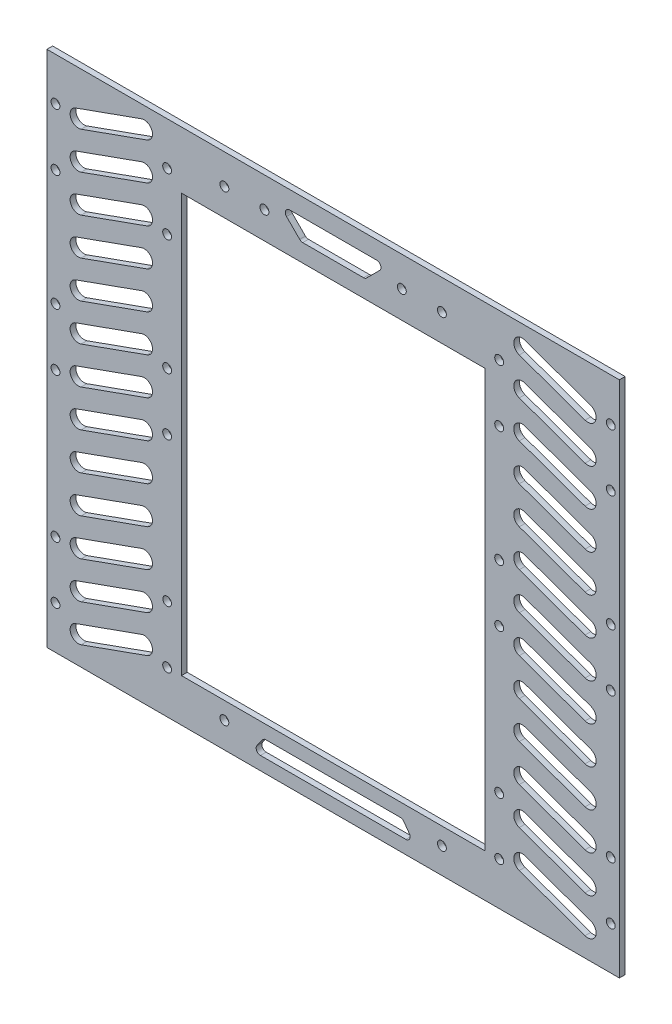
from build123d import *

# Parameters (mm, degrees)
SKETCH_1_R      = 1.55
SKETCH_1_R_2    = 1.51
SKETCH_1_W      = 106
SKETCH_1_H      = 146
EXTRUDE_1_DEPTH = 2


with BuildPart() as part:
    # 草图1 → 凸台-拉伸1 (new body)
    with BuildSketch(Plane.XY):
        Polygon((-100, 62.5), (-100, -62.5), (-100, -90.5), (100, -90.5), (100, -62.5), (100, 62.5), (100, 90.5), (-100, 90.5), align=None)
        with Locations((-97, -75.5)):
            Circle(SKETCH_1_R, mode=Mode.SUBTRACT)
        with Locations((-97, -55.5)):
            Circle(SKETCH_1_R, mode=Mode.SUBTRACT)
        with Locations((-97, 75.5)):
            Circle(SKETCH_1_R, mode=Mode.SUBTRACT)
        with Locations((-97, 55.5)):
            Circle(SKETCH_1_R, mode=Mode.SUBTRACT)
        with Locations((-97, -5)):
            Circle(SKETCH_1_R, mode=Mode.SUBTRACT)
        with Locations((-97, 15)):
            Circle(SKETCH_1_R, mode=Mode.SUBTRACT)
        with Locations((97, 75.5)):
            Circle(SKETCH_1_R, mode=Mode.SUBTRACT)
        with Locations((97, 55.5)):
            Circle(SKETCH_1_R, mode=Mode.SUBTRACT)
        with Locations((97, -55.5)):
            Circle(SKETCH_1_R, mode=Mode.SUBTRACT)
        with Locations((97, -75.5)):
            Circle(SKETCH_1_R, mode=Mode.SUBTRACT)
        with Locations((-58, 75.5)):
            Circle(SKETCH_1_R, mode=Mode.SUBTRACT)
        with Locations((-58, 55.5)):
            Circle(SKETCH_1_R, mode=Mode.SUBTRACT)
        with Locations((-58, -55.5)):
            Circle(SKETCH_1_R_2, mode=Mode.SUBTRACT)
        with Locations((-58, -75.5)):
            Circle(SKETCH_1_R, mode=Mode.SUBTRACT)
        with Locations((58, 75.5)):
            Circle(SKETCH_1_R, mode=Mode.SUBTRACT)
        with Locations((58, 55.5)):
            Circle(SKETCH_1_R, mode=Mode.SUBTRACT)
        with Locations((58, -75.5)):
            Circle(SKETCH_1_R, mode=Mode.SUBTRACT)
        with Locations((58, -55.5)):
            Circle(SKETCH_1_R, mode=Mode.SUBTRACT)
        with Locations((-58, -5)):
            Circle(SKETCH_1_R, mode=Mode.SUBTRACT)
        with Locations((-58, 15)):
            Circle(SKETCH_1_R, mode=Mode.SUBTRACT)
        with Locations((97, 15)):
            Circle(SKETCH_1_R, mode=Mode.SUBTRACT)
        with Locations((97, -5)):
            Circle(SKETCH_1_R, mode=Mode.SUBTRACT)
        with Locations((58, 15)):
            Circle(SKETCH_1_R, mode=Mode.SUBTRACT)
        with Locations((58, -5)):
            Circle(SKETCH_1_R, mode=Mode.SUBTRACT)
        with Locations((-38, 80)):
            Circle(SKETCH_1_R, mode=Mode.SUBTRACT)
        with Locations((-24, 80)):
            Circle(SKETCH_1_R, mode=Mode.SUBTRACT)
        with Locations((24, 80)):
            Circle(SKETCH_1_R, mode=Mode.SUBTRACT)
        with Locations((38, 80)):
            Circle(SKETCH_1_R, mode=Mode.SUBTRACT)
        with Locations((-38, -81.5)):
            Circle(SKETCH_1_R, mode=Mode.SUBTRACT)
        with Locations((38, -81.5)):
            Circle(SKETCH_1_R, mode=Mode.SUBTRACT)
        with Locations((0, -2.5)):
            Rectangle(SKETCH_1_W, SKETCH_1_H, mode=Mode.SUBTRACT)
        with BuildLine():
            Line((-65.024906734, 80.53970658), (-88.024906734, 72.307350493))
            ThreePointArc((-88.024906734, 72.307350493), (-91.724268106, 74.056525332), (-89.975093266, 77.755886704))
            Line((-89.975093266, 77.755886704), (-66.975093266, 85.988242791))
            ThreePointArc((-66.975093266, 85.988242791), (-63.275731894, 84.239067952), (-65.024906734, 80.53970658))
        make_face(mode=Mode.SUBTRACT)
        with BuildLine():
            Line((-65.024906734, 67.53970658), (-88.024906734, 59.307350493))
            ThreePointArc((-88.024906734, 59.307350493), (-91.724268106, 61.056525332), (-89.975093266, 64.755886704))
            Line((-89.975093266, 64.755886704), (-66.975093266, 72.988242791))
            ThreePointArc((-66.975093266, 72.988242791), (-63.275731894, 71.239067952), (-65.024906734, 67.53970658))
        make_face(mode=Mode.SUBTRACT)
        with BuildLine():
            Line((-65.024906734, 54.53970658), (-88.024906734, 46.307350493))
            ThreePointArc((-88.024906734, 46.307350493), (-91.724268106, 48.056525332), (-89.975093266, 51.755886704))
            Line((-89.975093266, 51.755886704), (-66.975093266, 59.988242791))
            ThreePointArc((-66.975093266, 59.988242791), (-63.275731894, 58.239067952), (-65.024906734, 54.53970658))
        make_face(mode=Mode.SUBTRACT)
        with BuildLine():
            Line((-65.024906734, 41.53970658), (-88.024906734, 33.307350493))
            ThreePointArc((-88.024906734, 33.307350493), (-91.724268106, 35.056525332), (-89.975093266, 38.755886704))
            Line((-89.975093266, 38.755886704), (-66.975093266, 46.988242791))
            ThreePointArc((-66.975093266, 46.988242791), (-63.275731894, 45.239067952), (-65.024906734, 41.53970658))
        make_face(mode=Mode.SUBTRACT)
        with BuildLine():
            Line((-65.024906734, 28.53970658), (-88.024906734, 20.307350493))
            ThreePointArc((-88.024906734, 20.307350493), (-91.724268106, 22.056525332), (-89.975093266, 25.755886704))
            Line((-89.975093266, 25.755886704), (-66.975093266, 33.988242791))
            ThreePointArc((-66.975093266, 33.988242791), (-63.275731894, 32.239067952), (-65.024906734, 28.53970658))
        make_face(mode=Mode.SUBTRACT)
        with BuildLine():
            Line((-65.024906734, 15.53970658), (-88.024906734, 7.307350493))
            ThreePointArc((-88.024906734, 7.307350493), (-91.724268106, 9.056525332), (-89.975093266, 12.755886704))
            Line((-89.975093266, 12.755886704), (-66.975093266, 20.988242791))
            ThreePointArc((-66.975093266, 20.988242791), (-63.275731894, 19.239067952), (-65.024906734, 15.53970658))
        make_face(mode=Mode.SUBTRACT)
        with BuildLine():
            Line((-65.024906734, 2.53970658), (-88.024906734, -5.692649507))
            ThreePointArc((-88.024906734, -5.692649507), (-91.724268106, -3.943474668), (-89.975093266, -0.244113296))
            Line((-89.975093266, -0.244113296), (-66.975093266, 7.988242791))
            ThreePointArc((-66.975093266, 7.988242791), (-63.275731894, 6.239067952), (-65.024906734, 2.53970658))
        make_face(mode=Mode.SUBTRACT)
        with BuildLine():
            Line((-65.024906734, -10.46029342), (-88.024906734, -18.692649507))
            ThreePointArc((-88.024906734, -18.692649507), (-91.724268106, -16.943474668), (-89.975093266, -13.244113296))
            Line((-89.975093266, -13.244113296), (-66.975093266, -5.011757209))
            ThreePointArc((-66.975093266, -5.011757209), (-63.275731894, -6.760932048), (-65.024906734, -10.46029342))
        make_face(mode=Mode.SUBTRACT)
        with BuildLine():
            Line((-65.024906734, -23.46029342), (-88.024906734, -31.692649507))
            ThreePointArc((-88.024906734, -31.692649507), (-91.724268106, -29.943474668), (-89.975093266, -26.244113296))
            Line((-89.975093266, -26.244113296), (-66.975093266, -18.011757209))
            ThreePointArc((-66.975093266, -18.011757209), (-63.275731894, -19.760932048), (-65.024906734, -23.46029342))
        make_face(mode=Mode.SUBTRACT)
        with BuildLine():
            Line((-65.024906734, -36.46029342), (-88.024906734, -44.692649507))
            ThreePointArc((-88.024906734, -44.692649507), (-91.724268106, -42.943474668), (-89.975093266, -39.244113296))
            Line((-89.975093266, -39.244113296), (-66.975093266, -31.011757209))
            ThreePointArc((-66.975093266, -31.011757209), (-63.275731894, -32.760932048), (-65.024906734, -36.46029342))
        make_face(mode=Mode.SUBTRACT)
        with BuildLine():
            Line((-65.024906734, -49.46029342), (-88.024906734, -57.692649507))
            ThreePointArc((-88.024906734, -57.692649507), (-91.724268106, -55.943474668), (-89.975093266, -52.244113296))
            Line((-89.975093266, -52.244113296), (-66.975093266, -44.011757209))
            ThreePointArc((-66.975093266, -44.011757209), (-63.275731894, -45.760932048), (-65.024906734, -49.46029342))
        make_face(mode=Mode.SUBTRACT)
        with BuildLine():
            Line((-65.024906734, -62.46029342), (-88.024906734, -70.692649507))
            ThreePointArc((-88.024906734, -70.692649507), (-91.724268106, -68.943474668), (-89.975093266, -65.244113296))
            Line((-89.975093266, -65.244113296), (-66.975093266, -57.011757209))
            ThreePointArc((-66.975093266, -57.011757209), (-63.275731894, -58.760932048), (-65.024906734, -62.46029342))
        make_face(mode=Mode.SUBTRACT)
        with BuildLine():
            Line((-65.024906734, -75.46029342), (-88.024906734, -83.692649507))
            ThreePointArc((-88.024906734, -83.692649507), (-91.724268106, -81.943474668), (-89.975093266, -78.244113296))
            Line((-89.975093266, -78.244113296), (-66.975093266, -70.011757209))
            ThreePointArc((-66.975093266, -70.011757209), (-63.275731894, -71.760932048), (-65.024906734, -75.46029342))
        make_face(mode=Mode.SUBTRACT)
        with BuildLine():
            Line((65.024906734, -75.46029342), (88.024906734, -83.692649507))
            ThreePointArc((88.024906734, -83.692649507), (91.724268106, -81.943474668), (89.975093266, -78.244113296))
            Line((89.975093266, -78.244113296), (66.975093266, -70.011757209))
            ThreePointArc((66.975093266, -70.011757209), (63.275731894, -71.760932048), (65.024906734, -75.46029342))
        make_face(mode=Mode.SUBTRACT)
        with BuildLine():
            Line((65.024906734, -62.46029342), (88.024906734, -70.692649507))
            ThreePointArc((88.024906734, -70.692649507), (91.724268106, -68.943474668), (89.975093266, -65.244113296))
            Line((89.975093266, -65.244113296), (66.975093266, -57.011757209))
            ThreePointArc((66.975093266, -57.011757209), (63.275731894, -58.760932048), (65.024906734, -62.46029342))
        make_face(mode=Mode.SUBTRACT)
        with BuildLine():
            Line((65.024906734, -49.46029342), (88.024906734, -57.692649507))
            ThreePointArc((88.024906734, -57.692649507), (91.724268106, -55.943474668), (89.975093266, -52.244113296))
            Line((89.975093266, -52.244113296), (66.975093266, -44.011757209))
            ThreePointArc((66.975093266, -44.011757209), (63.275731894, -45.760932048), (65.024906734, -49.46029342))
        make_face(mode=Mode.SUBTRACT)
        with BuildLine():
            Line((65.024906734, -36.46029342), (88.024906734, -44.692649507))
            ThreePointArc((88.024906734, -44.692649507), (91.724268106, -42.943474668), (89.975093266, -39.244113296))
            Line((89.975093266, -39.244113296), (66.975093266, -31.011757209))
            ThreePointArc((66.975093266, -31.011757209), (63.275731894, -32.760932048), (65.024906734, -36.46029342))
        make_face(mode=Mode.SUBTRACT)
        with BuildLine():
            Line((65.024906734, -23.46029342), (88.024906734, -31.692649507))
            ThreePointArc((88.024906734, -31.692649507), (91.724268106, -29.943474668), (89.975093266, -26.244113296))
            Line((89.975093266, -26.244113296), (66.975093266, -18.011757209))
            ThreePointArc((66.975093266, -18.011757209), (63.275731894, -19.760932048), (65.024906734, -23.46029342))
        make_face(mode=Mode.SUBTRACT)
        with BuildLine():
            Line((65.024906734, -10.46029342), (88.024906734, -18.692649507))
            ThreePointArc((88.024906734, -18.692649507), (91.724268106, -16.943474668), (89.975093266, -13.244113296))
            Line((89.975093266, -13.244113296), (66.975093266, -5.011757209))
            ThreePointArc((66.975093266, -5.011757209), (63.275731894, -6.760932048), (65.024906734, -10.46029342))
        make_face(mode=Mode.SUBTRACT)
        with BuildLine():
            Line((65.024906734, 2.53970658), (88.024906734, -5.692649507))
            ThreePointArc((88.024906734, -5.692649507), (91.724268106, -3.943474668), (89.975093266, -0.244113296))
            Line((89.975093266, -0.244113296), (66.975093266, 7.988242791))
            ThreePointArc((66.975093266, 7.988242791), (63.275731894, 6.239067952), (65.024906734, 2.53970658))
        make_face(mode=Mode.SUBTRACT)
        with BuildLine():
            Line((65.024906734, 15.53970658), (88.024906734, 7.307350493))
            ThreePointArc((88.024906734, 7.307350493), (91.724268106, 9.056525332), (89.975093266, 12.755886704))
            Line((89.975093266, 12.755886704), (66.975093266, 20.988242791))
            ThreePointArc((66.975093266, 20.988242791), (63.275731894, 19.239067952), (65.024906734, 15.53970658))
        make_face(mode=Mode.SUBTRACT)
        with BuildLine():
            Line((65.024906734, 28.53970658), (88.024906734, 20.307350493))
            ThreePointArc((88.024906734, 20.307350493), (91.724268106, 22.056525332), (89.975093266, 25.755886704))
            Line((89.975093266, 25.755886704), (66.975093266, 33.988242791))
            ThreePointArc((66.975093266, 33.988242791), (63.275731894, 32.239067952), (65.024906734, 28.53970658))
        make_face(mode=Mode.SUBTRACT)
        with BuildLine():
            Line((65.024906734, 41.53970658), (88.024906734, 33.307350493))
            ThreePointArc((88.024906734, 33.307350493), (91.724268106, 35.056525332), (89.975093266, 38.755886704))
            Line((89.975093266, 38.755886704), (66.975093266, 46.988242791))
            ThreePointArc((66.975093266, 46.988242791), (63.275731894, 45.239067952), (65.024906734, 41.53970658))
        make_face(mode=Mode.SUBTRACT)
        with BuildLine():
            Line((65.024906734, 54.53970658), (88.024906734, 46.307350493))
            ThreePointArc((88.024906734, 46.307350493), (91.724268106, 48.056525332), (89.975093266, 51.755886704))
            Line((89.975093266, 51.755886704), (66.975093266, 59.988242791))
            ThreePointArc((66.975093266, 59.988242791), (63.275731894, 58.239067952), (65.024906734, 54.53970658))
        make_face(mode=Mode.SUBTRACT)
        with BuildLine():
            Line((65.024906734, 67.53970658), (88.024906734, 59.307350493))
            ThreePointArc((88.024906734, 59.307350493), (91.724268106, 61.056525332), (89.975093266, 64.755886704))
            Line((89.975093266, 64.755886704), (66.975093266, 72.988242791))
            ThreePointArc((66.975093266, 72.988242791), (63.275731894, 71.239067952), (65.024906734, 67.53970658))
        make_face(mode=Mode.SUBTRACT)
        with BuildLine():
            Line((65.024906734, 80.53970658), (88.024906734, 72.307350493))
            ThreePointArc((88.024906734, 72.307350493), (91.724268106, 74.056525332), (89.975093266, 77.755886704))
            Line((89.975093266, 77.755886704), (66.975093266, 85.988242791))
            ThreePointArc((66.975093266, 85.988242791), (63.275731894, 84.239067952), (65.024906734, 80.53970658))
        make_face(mode=Mode.SUBTRACT)
        with BuildLine():
            Line((15.218002208, 84.305965233), (-15.218002208, 84.305965233))
            ThreePointArc((-15.218002208, 84.305965233), (-16.603821507, 83.379990382), (-16.27866238, 81.745305062))
            Line((-16.27866238, 81.745305062), (-11.677644091, 77.144286773))
            ThreePointArc((-11.677644091, 77.144286773), (-11.191009068, 76.819127646), (-10.61698392, 76.704946945))
            Line((-10.61698392, 76.704946945), (10.61698392, 76.704946945))
            ThreePointArc((10.61698392, 76.704946945), (11.191009068, 76.819127646), (11.677644091, 77.144286773))
            Line((11.677644091, 77.144286773), (16.27866238, 81.745305062))
            ThreePointArc((16.27866238, 81.745305062), (16.603821507, 83.379990382), (15.218002208, 84.305965233))
        make_face(mode=Mode.SUBTRACT)
        with BuildLine():
            Line((25.401950858, -85.855378709), (-25.401950858, -85.855378709))
            ThreePointArc((-25.401950858, -85.855378709), (-26.736654172, -85.039898295), (-26.620124938, -83.480134794))
            Line((-26.620124938, -83.480134794), (-24.688138047, -80.791174249))
            ThreePointArc((-24.688138047, -80.791174249), (-24.154483553, -80.33171485), (-23.469963966, -80.166418164))
            Line((-23.469963966, -80.166418164), (23.469963966, -80.166418164))
            ThreePointArc((23.469963966, -80.166418164), (24.154483553, -80.33171485), (24.688138047, -80.791174249))
            Line((24.688138047, -80.791174249), (26.620124938, -83.480134794))
            ThreePointArc((26.620124938, -83.480134794), (26.736654172, -85.039898295), (25.401950858, -85.855378709))
        make_face(mode=Mode.SUBTRACT)
    extrude(amount=EXTRUDE_1_DEPTH)


solid = part.part
